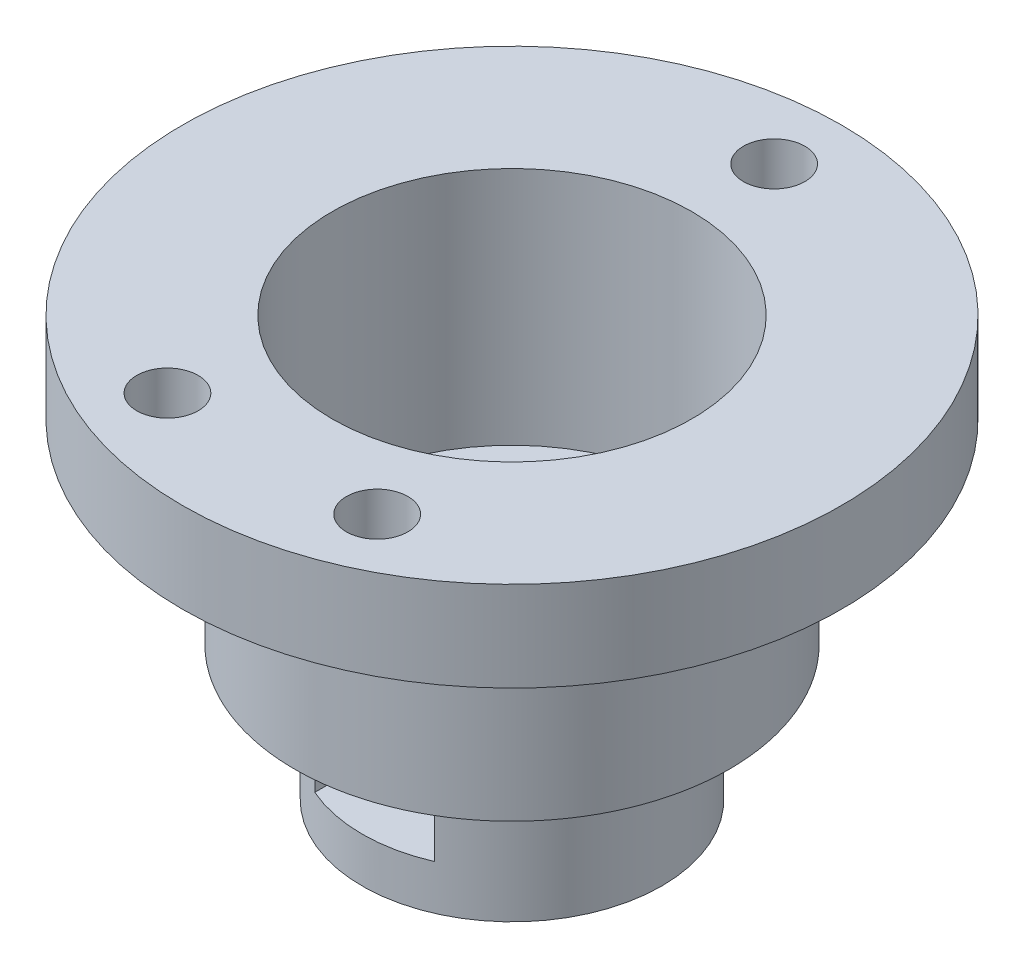
from build123d import *

# Parameters (mm, degrees)
SKETCH1_R           = 10
BOSS_EXTRUDE1_DEPTH = 9
SKETCH2_R           = 14.5
BOSS_EXTRUDE2_DEPTH = 3
SKETCH3_R           = 14.5
SKETCH3_R_2         = 12
BOSS_EXTRUDE3_DEPTH = 10
SKETCH4_R           = 3
CUT_EXTRUDE1_DEPTH  = 13
BOSS_EXTRUDE4_REACH = 24
SKETCH5_R           = 1.5
CUT_EXTRUDE2_DEPTH  = 3.8
SKETCH7_R           = 22
SKETCH7_R_2         = 12
BOSS_EXTRUDE5_DEPTH = 6
SKETCH8_R           = 2.05
CUT_EXTRUDE3_DEPTH  = 5


with BuildPart() as part:
    # Sketch1 → Boss-Extrude1 (new body)
    with BuildSketch(Plane(origin=(0, 0, 0), x_dir=(1, 0, 0), z_dir=(0, 1, 0))):
        Circle(SKETCH1_R)
    extrude(amount=BOSS_EXTRUDE1_DEPTH)

    # Sketch2 → Boss-Extrude2 (add)
    with BuildSketch(Plane(origin=(0, 9, 0), x_dir=(1, 0, 0), z_dir=(0, 1, 0))):
        Circle(SKETCH2_R)
    extrude(amount=BOSS_EXTRUDE2_DEPTH)

    # Sketch3 → Boss-Extrude3 (add)
    with BuildSketch(Plane(origin=(0, 12, 0), x_dir=(1, 0, 0), z_dir=(0, 1, 0))):
        Circle(SKETCH3_R)
        Circle(SKETCH3_R_2, mode=Mode.SUBTRACT)
    extrude(amount=BOSS_EXTRUDE3_DEPTH)

    # Sketch4 → Cut-Extrude1 (cut, through all)
    with BuildSketch(Plane(origin=(0, 12, 0), x_dir=(1, 0, 0), z_dir=(0, 1, 0))):
        Circle(SKETCH4_R)
    extrude(amount=-CUT_EXTRUDE1_DEPTH, mode=Mode.SUBTRACT)

    # Sketch5 → Boss-Extrude4 (add, up to next)
    with BuildSketch(Plane.XZ, mode=Mode.PRIVATE) as boss_extrude4_sk1:
        with Locations((-13, 0)):
            Circle(SKETCH5_R)
    boss_extrude4_tool1 = extrude(boss_extrude4_sk1.sketch, amount=-BOSS_EXTRUDE4_REACH, mode=Mode.PRIVATE) - part.part
    add(boss_extrude4_tool1.solids().sort_by_distance((-13, 0, 0))[0])
    # Sketch5 → Boss-Extrude4 (add, up to next)
    with BuildSketch(Plane.XZ, mode=Mode.PRIVATE) as boss_extrude4_sk2:
        with BuildLine():
            ThreePointArc((-9.886859967, -1.5), (-10, 0), (-9.886859967, 1.5))
            Line((-9.886859967, 1.5), (-13, 1.5))
            ThreePointArc((-13, 1.5), (-11.939339828, 1.060660172), (-11.5, 0))
            ThreePointArc((-11.5, 0), (-11.939339828, -1.060660172), (-13, -1.5))
            Line((-13, -1.5), (-9.886859967, -1.5))
        make_face()
    boss_extrude4_tool2 = extrude(boss_extrude4_sk2.sketch, amount=-BOSS_EXTRUDE4_REACH, mode=Mode.PRIVATE) - part.part
    add(boss_extrude4_tool2.solids().sort_by_distance((-10.921971, 0, 0))[0])

    # Sketch6 → Cut-Extrude2 (cut)
    with BuildSketch(Plane(origin=(0, 3, 0), x_dir=(-1, 0, 0), z_dir=(0, -1, 0))):
        with BuildLine():
            Line((4, -2.309401077), (4, 2.309401077))
            Line((4, 2.309401077), (0, 4.618802154))
            Line((0, 4.618802154), (-4, 2.309401077))
            Line((-4, 2.309401077), (-4, -2.309401077))
            Line((-4, -2.309401077), (-4, -9.16515139))
            ThreePointArc((-4, -9.16515139), (0, -10), (4, -9.16515139))
            Line((4, -9.16515139), (4, -2.309401077))
        make_face()
    extrude(amount=-CUT_EXTRUDE2_DEPTH, mode=Mode.SUBTRACT)

    # Sketch7 → Boss-Extrude5 (add)
    with BuildSketch(Plane(origin=(0, 22, 0), x_dir=(1, 0, 0), z_dir=(0, 1, 0))):
        Circle(SKETCH7_R)
        Circle(SKETCH7_R_2, mode=Mode.SUBTRACT)
    extrude(amount=BOSS_EXTRUDE5_DEPTH)

    # Sketch8 → Cut-Extrude3 (cut)
    with BuildSketch(Plane(origin=(0, 28, 0), x_dir=(1, 0, 0), z_dir=(0, 1, 0))):
        with Locations((0, 17.5)):
            Circle(SKETCH8_R)
        with Locations((-7, -16)):
            Circle(SKETCH8_R)
        with Locations((7, -16)):
            Circle(SKETCH8_R)
    extrude(amount=-CUT_EXTRUDE3_DEPTH, mode=Mode.SUBTRACT)


solid = part.part
